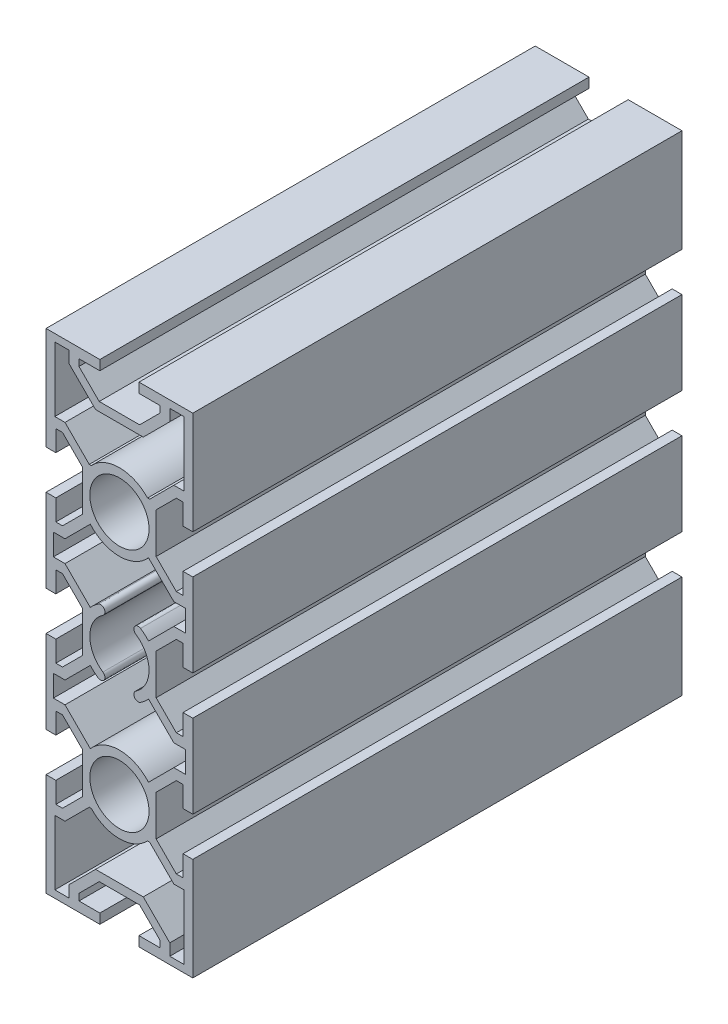
from build123d import *

# Parameters (mm, degrees)
MB1_2_R        = 6.049999109
MB1_2_R_2      = 6.050000891
EXTRUDE1_DEPTH = 100


with BuildPart() as part:
    # MB1-2 → Extrude1 (new body)
    with BuildSketch(Plane.XY):
        Polygon((-13, -33.265685), (-11.634315, -33.265685), (-7.5, -29.131371165), (-7.5, -20.868628835), (-11.634315, -16.734315), (-13, -16.734315), (-13, -21), (-15, -21), (-15, -4), (-13, -4), (-13, -8.265685), (-11.634315, -8.265685), (-7.5, -4.131371165), (-7.5, 4.131371165), (-11.634315, 8.265685), (-13, 8.265685), (-13, 4), (-15, 4), (-15, 21), (-13, 21), (-13, 16.734315), (-11.634315, 16.734315), (-7.5, 20.868628835), (-7.5, 29.131371165), (-11.634315, 33.265685), (-13, 33.265685), (-13, 29), (-15, 29), (-15, 50), (-4, 50), (-4, 48), (-8.265685, 48), (-8.265685, 46.634315), (-4.131371165, 42.5), (4.131371165, 42.5), (8.265685, 46.634315), (8.265685, 48), (4, 48), (4, 50), (15, 50), (15, 29), (13, 29), (13, 33.265685), (11.634315, 33.265685), (7.5, 29.131371165), (7.5, 20.868628835), (11.634315, 16.734315), (13, 16.734315), (13, 21), (15, 21), (15, 4), (13, 4), (13, 8.265685), (11.634315, 8.265685), (7.5, 4.131371165), (7.5, -4.131371165), (11.634315, -8.265685), (13, -8.265685), (13, -4), (15, -4), (15, -21), (13, -21), (13, -16.734315), (11.634315, -16.734315), (7.5, -20.868628835), (7.5, -29.131371165), (11.634315, -33.265685), (13, -33.265685), (13, -29), (15, -29), (15, -50), (4, -50), (4, -48), (8.265685, -48), (8.265685, -46.634315), (4.131371165, -42.5), (-4.131371165, -42.5), (-8.265685, -46.634315), (-8.265685, -48), (-4, -48), (-4, -50), (-15, -50), (-15, -29), (-13, -29), align=None)
        with Locations((0, -24.999996952)):
            Circle(MB1_2_R, mode=Mode.SUBTRACT)
        with Locations((0, 24.999996952)):
            Circle(MB1_2_R_2, mode=Mode.SUBTRACT)
        with BuildLine():
            Line((5.74819726, -30.346094347), (6.169137939, -30.346093939))
            Line((6.169137939, -30.346093939), (11.123044, -35.3))
            Line((11.123044, -35.3), (13.2, -35.3))
            Line((13.2, -35.3), (13.2, -48.5))
            Line((13.2, -48.5), (10.3, -48.5))
            Line((10.3, -48.5), (10.3, -46.123043785))
            Line((10.3, -46.123043785), (4.876954686, -40.7))
            Line((4.876954686, -40.7), (-4.876954686, -40.7))
            Line((-4.876954686, -40.7), (-10.3, -46.123043785))
            Line((-10.3, -46.123043785), (-10.3, -48.5))
            Line((-10.3, -48.5), (-13.2, -48.5))
            Line((-13.2, -48.5), (-13.2, -35.3))
            Line((-13.2, -35.3), (-11.123044, -35.3))
            Line((-11.123044, -35.3), (-6.169138347, -30.346094347))
            Line((-6.169138347, -30.346094347), (-5.74819688, -30.346094756))
            ThreePointArc((-5.74819688, -30.346094756), (2.79e-07, -32.849998806), (5.74819726, -30.346094347))
        make_face(mode=Mode.SUBTRACT)
        with BuildLine():
            Line((6.169138347, 30.346094347), (5.74819688, 30.346094756))
            ThreePointArc((5.74819688, 30.346094756), (-2.79e-07, 32.849998806), (-5.74819726, 30.346094347))
            Line((-5.74819726, 30.346094347), (-6.169137939, 30.346093939))
            Line((-6.169137939, 30.346093939), (-11.123044, 35.3))
            Line((-11.123044, 35.3), (-13.2, 35.3))
            Line((-13.2, 35.3), (-13.2, 48.5))
            Line((-13.2, 48.5), (-10.3, 48.5))
            Line((-10.3, 48.5), (-10.3, 46.123043785))
            Line((-10.3, 46.123043785), (-4.876954686, 40.7))
            Line((-4.876954686, 40.7), (4.876954686, 40.7))
            Line((4.876954686, 40.7), (10.3, 46.123043785))
            Line((10.3, 46.123043785), (10.3, 48.5))
            Line((10.3, 48.5), (13.2, 48.5))
            Line((13.2, 48.5), (13.2, 35.3))
            Line((13.2, 35.3), (11.123044, 35.3))
            Line((11.123044, 35.3), (6.169138347, 30.346094347))
        make_face(mode=Mode.SUBTRACT)
        with BuildLine():
            Line((-11.123044, -14.7), (-5.947034494, -19.876009506))
            ThreePointArc((-5.947034494, -19.876009506), (0, -17.149999078), (5.947034494, -19.876009506))
            Line((5.947034494, -19.876009506), (11.123044, -14.7))
            Line((11.123044, -14.7), (13.5, -14.7))
            Line((13.5, -14.7), (13.5, -10.3))
            Line((13.5, -10.3), (11.123044, -10.3))
            Line((11.123044, -10.3), (5.947034535, -5.123990535))
            ThreePointArc((5.947034535, -5.123990535), (5.181974313, -5.896578485), (4.3175, -6.556043))
            ThreePointArc((4.3175, -6.556043), (3.079734534, -6.258736768), (3.375725, -5.020656))
            ThreePointArc((3.375725, -5.020656), (6.050002522, 0), (3.375725, 5.020656))
            ThreePointArc((3.375725, 5.020656), (3.078919, 6.259237), (4.3175, 6.556043))
            ThreePointArc((4.3175, 6.556043), (5.181974313, 5.896578485), (5.947034535, 5.123990535))
            Line((5.947034535, 5.123990535), (11.123044, 10.3))
            Line((11.123044, 10.3), (13.5, 10.3))
            Line((13.5, 10.3), (13.5, 14.7))
            Line((13.5, 14.7), (11.123044, 14.7))
            Line((11.123044, 14.7), (5.947034494, 19.876009506))
            ThreePointArc((5.947034494, 19.876009506), (0, 17.149999078), (-5.947034494, 19.876009506))
            Line((-5.947034494, 19.876009506), (-11.123044, 14.7))
            Line((-11.123044, 14.7), (-13.5, 14.7))
            Line((-13.5, 14.7), (-13.5, 10.3))
            Line((-13.5, 10.3), (-11.123044, 10.3))
            Line((-11.123044, 10.3), (-5.947034535, 5.123990535))
            ThreePointArc((-5.947034535, 5.123990535), (-5.181974313, 5.896578485), (-4.3175, 6.556043))
            ThreePointArc((-4.3175, 6.556043), (-3.079734534, 6.258736768), (-3.375725, 5.020656))
            ThreePointArc((-3.375725, 5.020656), (-6.049998461, 0), (-3.375725, -5.020656))
            ThreePointArc((-3.375725, -5.020656), (-3.079734534, -6.258736768), (-4.3175, -6.556043))
            ThreePointArc((-4.3175, -6.556043), (-5.181974313, -5.896578485), (-5.947034535, -5.123990535))
            Line((-5.947034535, -5.123990535), (-11.123044, -10.3))
            Line((-11.123044, -10.3), (-13.5, -10.3))
            Line((-13.5, -10.3), (-13.5, -14.7))
            Line((-13.5, -14.7), (-11.123044, -14.7))
        make_face(mode=Mode.SUBTRACT)
    extrude(amount=-EXTRUDE1_DEPTH)


solid = part.part
